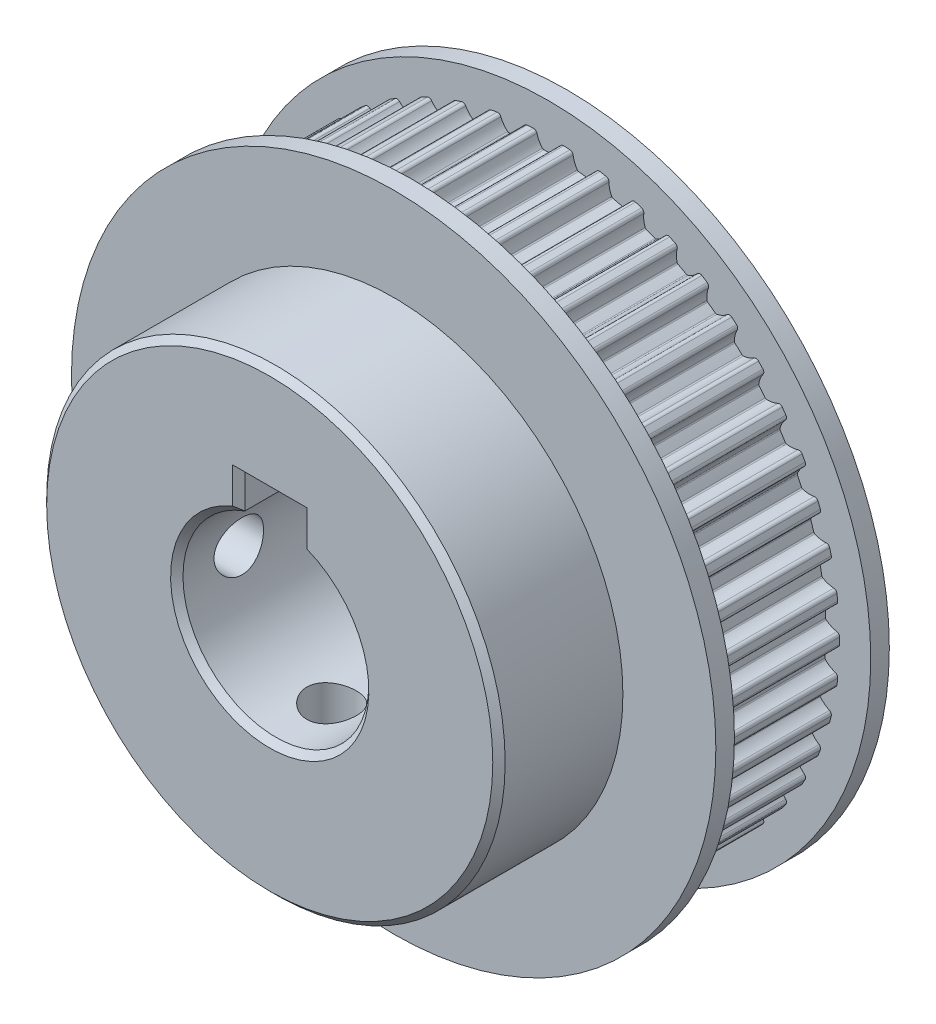
from build123d import *

# Parameters (mm, degrees)
SKETCH_1_R               = 23.49
EXTRUDE_1_DEPTH          = 5.5
CUT_EXTRUDE_START        = -12
CUT_EXTRUDE_1_DEPTH      = 13
PATTERN_CIRCULAR_1_COUNT = 50
SKETCH_3_R               = 26
EXTRUDE_2_DEPTH          = 1.5
SKETCH_9_R               = 26
EXTRUDE_3_DEPTH          = 1.5
SKETCH_12_R              = 18.5
EXTRUDE_4_DEPTH          = 10
SKETCH_4_R               = 7.5
CUT_EXTRUDE_2_DEPTH      = 11
CUT_EXTRUDE_2_DEPTH_BACK = 15
SKETCH_13_W              = 5
SKETCH_13_H              = 2.728932188
CUT_EXTRUDE_5_DEPTH      = 25
SKETCH_10_R              = 2
CUT_EXTRUDE_3_DEPTH      = 27
CHAMFER_1_SIZE           = 0.5
PATTERN_CIRCULAR_2_COUNT = 2
PATTERN_CIRCULAR_2_ANGLE = 90


with BuildPart() as part:
    # 草圖1 → 填料-伸長1 (new body, symmetric)
    with BuildSketch(Plane.XY):
        Circle(SKETCH_1_R)
    extrude(amount=EXTRUDE_1_DEPTH, both=True)

    # 草圖2 → 除料-伸長1 (cut)
    with BuildSketch(Plane.XY.offset(5.5).offset(CUT_EXTRUDE_START)):
        with BuildLine():
            ThreePointArc((-0.38216, 22.376736888), (0, 22.38), (0.38216, 22.376736888))
            ThreePointArc((0.38216, 22.376736888), (0.444756005, 22.389252857), (0.496479317, 22.426664196))
            ThreePointArc((0.496479317, 22.426664196), (0.765911201, 22.811340796), (0.93689934, 23.248756711))
            ThreePointArc((0.93689934, 23.248756711), (1.042397635, 23.404357495), (1.22252589, 23.458165539))
            ThreePointArc((1.22252589, 23.458165539), (0, 23.49), (-1.22252589, 23.458165539))
            ThreePointArc((-1.22252589, 23.458165539), (-1.042397635, 23.404357495), (-0.93689934, 23.248756711))
            ThreePointArc((-0.93689934, 23.248756711), (-0.765911201, 22.811340796), (-0.496479317, 22.426664196))
            ThreePointArc((-0.496479317, 22.426664196), (-0.444756005, 22.389252857), (-0.38216, 22.376736888))
        make_face()
    cut_extrude_1 = extrude(amount=CUT_EXTRUDE_1_DEPTH, mode=Mode.SUBTRACT)

    # 環狀複製排列1: 除料-伸長1 ×50 about axis
    pattern_circular_1_axis = Axis((0, 0, 0), (0, 0, 1))
    for i in range(1, PATTERN_CIRCULAR_1_COUNT):
        add(cut_extrude_1.rotate(pattern_circular_1_axis, i * 360 / PATTERN_CIRCULAR_1_COUNT), mode=Mode.SUBTRACT)

    # 草圖3 → 填料-伸長2 (add)
    with BuildSketch(Plane.XY.offset(5.5)):
        Circle(SKETCH_3_R)
    extrude(amount=EXTRUDE_2_DEPTH)

    # 草圖9 → 填料-伸長3 (add)
    with BuildSketch(Plane(origin=(0, 0, -5.5), x_dir=(-1, 0, 0), z_dir=(0, 0, -1))):
        Circle(SKETCH_9_R)
    extrude(amount=EXTRUDE_3_DEPTH)

    # 草圖12 → 填料-伸長4 (add)
    with BuildSketch(Plane.XY.offset(7)):
        Circle(SKETCH_12_R)
    extrude(amount=EXTRUDE_4_DEPTH)

    # 草圖4 → 除料-伸長2 (cut, two sides)
    with BuildSketch(Plane.XY.offset(7)) as cut_extrude_2_sk:
        Circle(SKETCH_4_R)
    extrude(amount=CUT_EXTRUDE_2_DEPTH, mode=Mode.SUBTRACT)
    extrude(cut_extrude_2_sk.sketch, amount=-CUT_EXTRUDE_2_DEPTH_BACK, mode=Mode.SUBTRACT)

    # 草圖13 → 除料-伸長5 (cut, through all)
    with BuildSketch(Plane.XY.offset(17)):
        with Locations((0, 8.435533906)):
            Rectangle(SKETCH_13_W, SKETCH_13_H)
    extrude(amount=-CUT_EXTRUDE_5_DEPTH, mode=Mode.SUBTRACT)

    # 草圖10 → 除料-伸長3 (cut, through all)
    with BuildSketch(Plane(origin=(0, 0, 0), x_dir=(1, 0, 0), z_dir=(0, 1, 0))):
        with Locations((0, -12)):
            Circle(SKETCH_10_R)
    cut_extrude_3 = extrude(amount=-CUT_EXTRUDE_3_DEPTH, mode=Mode.SUBTRACT)

    # 導角1
    chamfer_1_edges = [part.edges().sort_by_distance(p)[0] for p in [
        (-18.5, 0, 17),
        (0, -7.5, -7),
        (0, -7.5, 17),
        (-2.5, 8.435533906, 17),
        (2.5, 8.435533906, 17),
        (0, 9.8, 17),
        (2.5, 8.435533906, -7),
        (-2.5, 8.435533906, -7),
        (0, 9.8, -7),
    ]]
    chamfer(chamfer_1_edges, length=CHAMFER_1_SIZE)

    # 環狀複製排列2: 除料-伸長3 ×2 about axis
    pattern_circular_2_axis = Axis((0, 0, 7), (0, 0, -1))
    for i in range(1, PATTERN_CIRCULAR_2_COUNT):
        add(cut_extrude_3.rotate(pattern_circular_2_axis, i * PATTERN_CIRCULAR_2_ANGLE / (PATTERN_CIRCULAR_2_COUNT - 1)), mode=Mode.SUBTRACT)


solid = part.part
